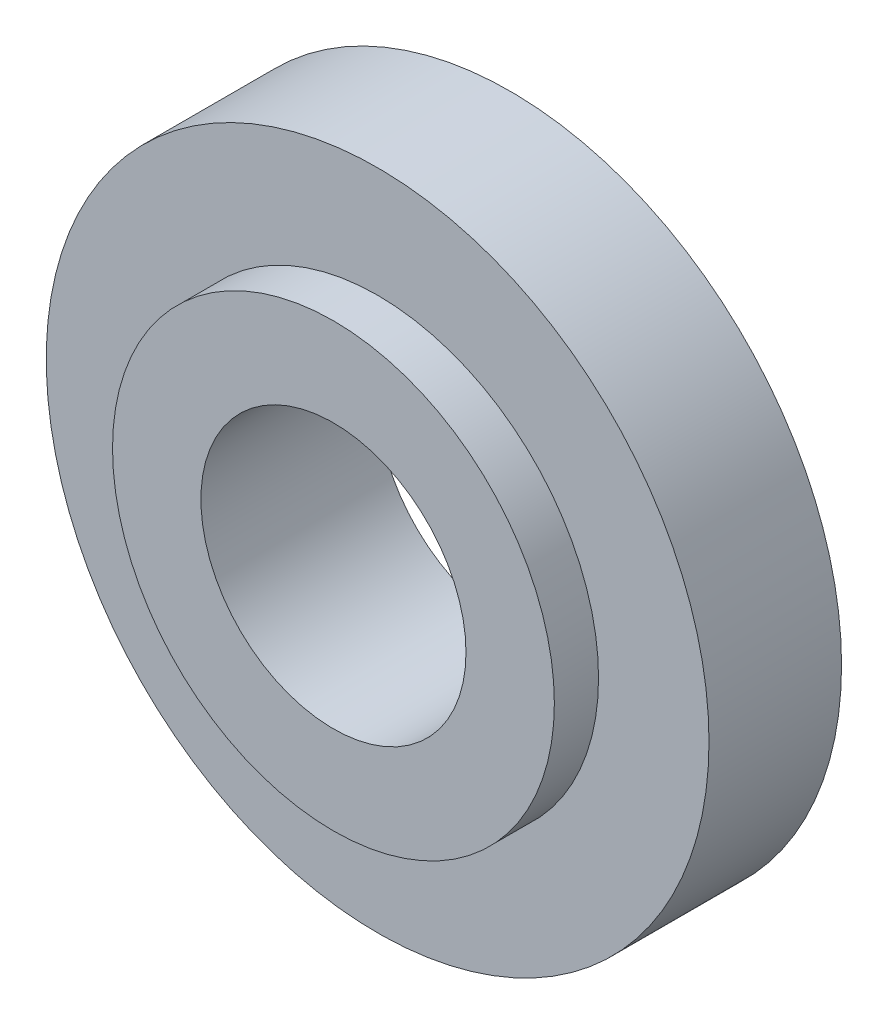
from build123d import *

# Parameters (mm, degrees)
SKETCH1_R           = 3.75
SKETCH1_R_2         = 2.5
BOSS_EXTRUDE1_DEPTH = 1.5
SKETCH1_3_R         = 2.5
SKETCH1_3_R_2       = 1.5
BOSS_EXTRUDE2_DEPTH = 2


with BuildPart() as part:
    # Sketch1 → Boss-Extrude1 (new body)
    with BuildSketch(Plane.XY):
        Circle(SKETCH1_R)
        Circle(SKETCH1_R_2, mode=Mode.SUBTRACT)
    extrude(amount=BOSS_EXTRUDE1_DEPTH)

    # Sketch1_3 → Boss-Extrude2 (add)
    with BuildSketch(Plane.XY):
        Circle(SKETCH1_3_R)
        Circle(SKETCH1_3_R_2, mode=Mode.SUBTRACT)
    extrude(amount=BOSS_EXTRUDE2_DEPTH)


solid = part.part
